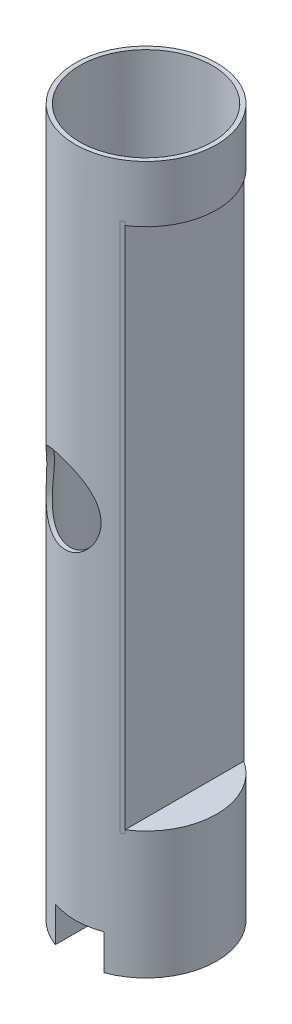
from build123d import *

# Parameters (mm, degrees)
SKETCH1_R               = 50.8
BOSS_EXTRUDE1_DEPTH     = 457.2
SKETCH2_R               = 47.625
CUT_EXTRUDE1_DEPTH      = 458.2
SKETCH3_R               = 27.989032433
SKETCH3_W               = 25.4
SKETCH3_H               = 381
CUT_EXTRUDE3_DEPTH      = 51.8
CUT_EXTRUDE3_DEPTH_BACK = 51.8
BOSS_EXTRUDE2_DEPTH     = 381
SKETCH6_R               = 50.8
BOSS_EXTRUDE3_DEPTH     = 50.8
CUT_EXTRUDE4_DEPTH      = 25.4
SKETCH8_R               = 3.302
CUT_EXTRUDE5_DEPTH      = 73.916768016
BOSS_EXTRUDE4_DEPTH     = 2.54
BOSS_EXTRUDE5_DEPTH     = 2.54
SKETCH26_W              = 12.7
SKETCH26_H              = 19.05
CUT_EXTRUDE6_DEPTH      = 84.582


with BuildPart() as part:
    # Sketch1 → Boss-Extrude1 (new body)
    with BuildSketch(Plane(origin=(0, 0, 0), x_dir=(1, 0, 0), z_dir=(0, 1, 0))):
        Circle(SKETCH1_R)
    extrude(amount=BOSS_EXTRUDE1_DEPTH)

    # Sketch2 → Cut-Extrude1 (cut, through all)
    with BuildSketch(Plane(origin=(0, 457.2, 0), x_dir=(1, 0, 0), z_dir=(0, 1, 0))):
        Circle(SKETCH2_R)
    extrude(amount=-CUT_EXTRUDE1_DEPTH, mode=Mode.SUBTRACT)

    # Sketch3 → Cut-Extrude3 (cut, two sides)
    with BuildSketch(Plane.XY) as cut_extrude3_sk:
        with Locations((-12.065, 228.6)):
            Circle(SKETCH3_R)
        with Locations((38.1, 228.6)):
            Rectangle(SKETCH3_W, SKETCH3_H)
    extrude(amount=CUT_EXTRUDE3_DEPTH, mode=Mode.SUBTRACT)
    extrude(cut_extrude3_sk.sketch, amount=-CUT_EXTRUDE3_DEPTH_BACK, mode=Mode.SUBTRACT)

    # Sketch5 → Boss-Extrude2 (add)
    with BuildSketch(Plane(origin=(0, 38.1, 0), x_dir=(1, 0, 0), z_dir=(0, 1, 0))):
        Polygon((25.4, -43.994090512), (25.4, 43.994090512), (27.573729132, 42.665319192), (27.573729132, -42.665319192), align=None)
    extrude(amount=BOSS_EXTRUDE2_DEPTH)

    # Sketch6 → Boss-Extrude3 (add)
    with BuildSketch(Plane.XZ):
        Circle(SKETCH6_R)
    extrude(amount=BOSS_EXTRUDE3_DEPTH)

    # Sketch7 → Cut-Extrude4 (cut)
    with BuildSketch(Plane.XZ.offset(50.8)):
        with BuildLine():
            Line((17.374623281, 47.736385136), (17.374623281, 22.116767912))
            Line((17.374623281, 22.116767912), (-17.374623281, 22.116767912))
            Line((-17.374623281, 22.116767912), (-17.374623281, 47.736385136))
            ThreePointArc((-17.374623281, 47.736385136), (-8.821327425, 50.028233853), (0, 50.8))
            ThreePointArc((0, 50.8), (8.821327425, 50.028233853), (17.374623281, 47.736385136))
        make_face()
        with BuildLine():
            Line((17.374623281, -22.116767912), (-17.374623281, -22.116767912))
            Line((-17.374623281, -22.116767912), (-17.374623281, -47.736385136))
            ThreePointArc((-17.374623281, -47.736385136), (-8.821327425, -50.028233853), (0, -50.8))
            ThreePointArc((0, -50.8), (8.821327425, -50.028233853), (17.374623281, -47.736385136))
            Line((17.374623281, -47.736385136), (17.374623281, -22.116767912))
        make_face()
    extrude(amount=-CUT_EXTRUDE4_DEPTH, mode=Mode.SUBTRACT)

    # Sketch8 → Cut-Extrude5 (cut, through all)
    with BuildSketch(Plane.XY.offset(22.116767912)):
        with Locations((0, -38.091466754)):
            Circle(SKETCH8_R)
    extrude(amount=-CUT_EXTRUDE5_DEPTH, mode=Mode.SUBTRACT)

    # Sketch9 → Boss-Extrude4 (add)
    with BuildSketch(Plane(origin=(0, 38.1, 0), x_dir=(1, 0, 0), z_dir=(0, 1, 0))):
        with BuildLine():
            Line((27.573729132, 42.665319192), (27.573729132, -42.665319192))
            ThreePointArc((27.573729132, -42.665319192), (50.8, 0), (27.573729132, 42.665319192))
        make_face()
    extrude(amount=BOSS_EXTRUDE4_DEPTH)

    # Sketch10 → Boss-Extrude5 (add)
    with BuildSketch(Plane.XZ.offset(-419.1)):
        with BuildLine():
            Line((27.573729132, 42.665319192), (27.573729132, -42.665319192))
            ThreePointArc((27.573729132, -42.665319192), (50.8, 0), (27.573729132, 42.665319192))
        make_face()
    extrude(amount=BOSS_EXTRUDE5_DEPTH)

    # Sketch26 → Cut-Extrude6 (cut)
    with BuildSketch(Plane.XZ.offset(50.8)):
        Rectangle(SKETCH26_W, SKETCH26_H)
    extrude(amount=-CUT_EXTRUDE6_DEPTH, mode=Mode.SUBTRACT)


solid = part.part
